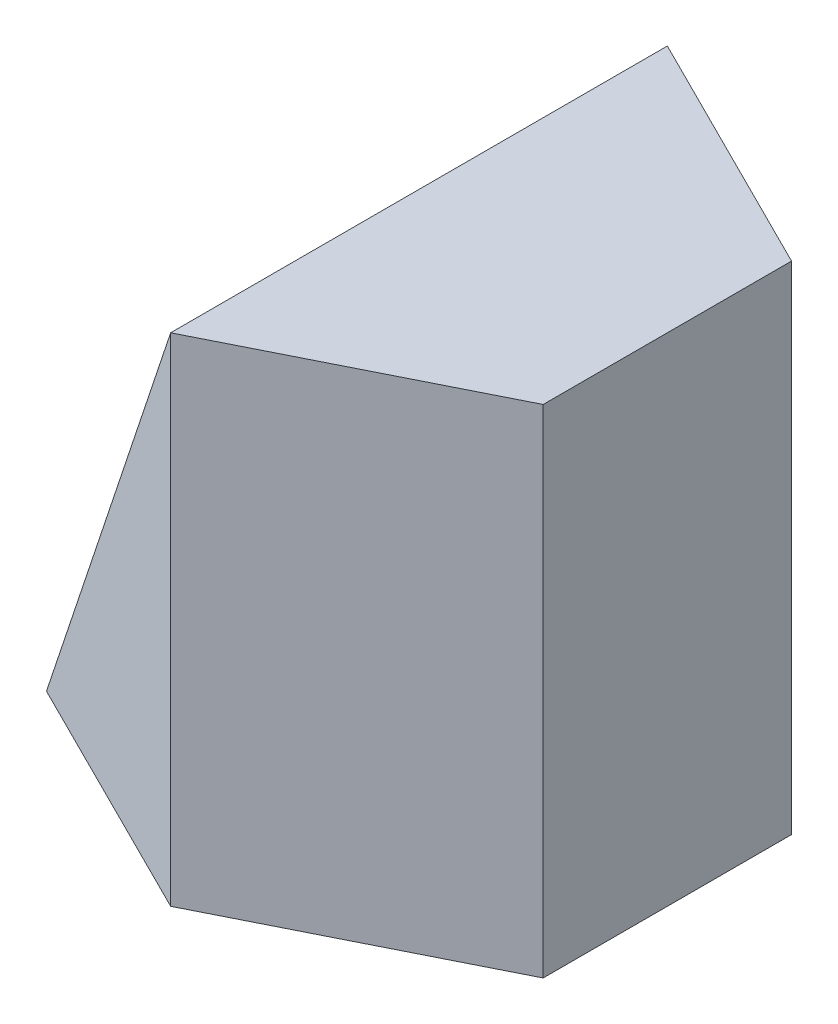
from build123d import *

# Parameters (mm, degrees)
SKETCH1_W           = 40
SKETCH1_H           = 40
BOSS_EXTRUDE1_DEPTH = 40
CUT_EXTRUDE1_DEPTH  = 40
CUT_EXTRUDE2_DEPTH  = 40


with BuildPart() as part:
    # Sketch1 → Boss-Extrude1 (new body)
    with BuildSketch(Plane.XY):
        with Locations((20, 20)):
            Rectangle(SKETCH1_W, SKETCH1_H)
    extrude(amount=BOSS_EXTRUDE1_DEPTH)

    # Sketch2 → Cut-Extrude1 (cut)
    with BuildSketch(Plane.XY.offset(40)):
        Polygon((0, 0), (20, 40), (0, 40), align=None)
    extrude(amount=-CUT_EXTRUDE1_DEPTH, mode=Mode.SUBTRACT)

    # Sketch3 → Cut-Extrude2 (cut)
    with BuildSketch(Plane.XZ):
        Polygon((0, 40), (0, 30), (20, 40), align=None)
        Polygon((0, 0), (20, 0), (0, 10), align=None)
        Polygon((20, 40), (40, 30), (40, 40), align=None)
        Polygon((40, 10), (20, 0), (40, 0), align=None)
    extrude(amount=-CUT_EXTRUDE2_DEPTH, mode=Mode.SUBTRACT)


solid = part.part
